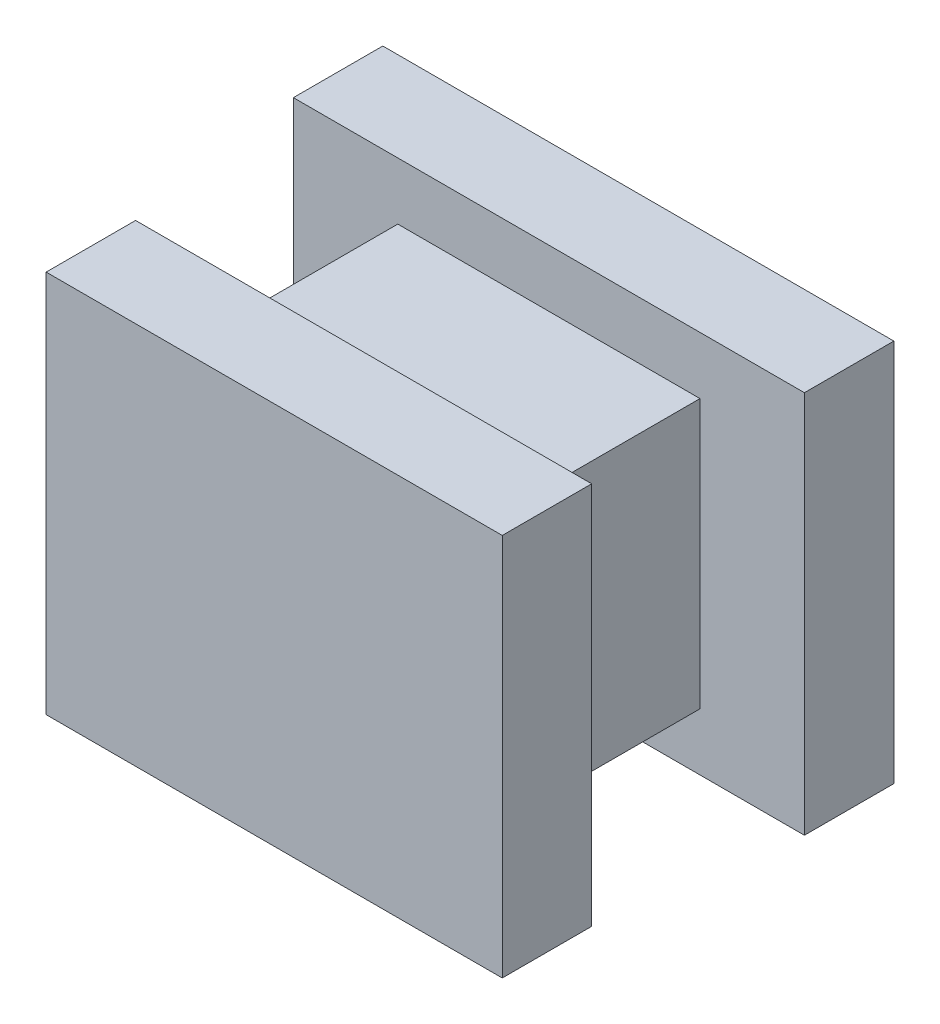
from build123d import *

# Parameters (mm, degrees)
SKETCH_1_W      = 4
SKETCH_1_H      = 3
EXTRUDE_1_DEPTH = 0.7
SKETCH_2_W      = 1.965469396
SKETCH_2_H      = 1.702913888
EXTRUDE_2_DEPTH = 1.45
SKETCH_4_W      = 3.57
SKETCH_4_H      = 3
EXTRUDE_3_DEPTH = 0.7
EXTRUDE_4_REACH = 4.15
SKETCH_7_W      = 2.365469396
SKETCH_7_H      = 2.102913888


with BuildPart() as part:
    # Эскиз1 → Бобышка-Вытянуть1 (new body)
    with BuildSketch(Plane.XY):
        Rectangle(SKETCH_1_W, SKETCH_1_H)
    extrude(amount=EXTRUDE_1_DEPTH)

    # Эскиз2 → Бобышка-Вытянуть2 (add)
    with BuildSketch(Plane.XY.offset(0.7)):
        Rectangle(SKETCH_2_W, SKETCH_2_H)
    extrude(amount=EXTRUDE_2_DEPTH)

    # Эскиз4 → Бобышка-Вытянуть3 (add)
    with BuildSketch(Plane.XY.offset(2.15)):
        Rectangle(SKETCH_4_W, SKETCH_4_H)
    extrude(amount=EXTRUDE_3_DEPTH)


with BuildPart() as body_2:

    # Эскиз7 → Бобышка-Вытянуть4 (new body, up to next)
    with BuildSketch(Plane.XY.offset(0.7), mode=Mode.PRIVATE) as extrude_4_sk1:
        Rectangle(SKETCH_7_W, SKETCH_7_H)
    extrude_4_tool1 = extrude(extrude_4_sk1.sketch, amount=EXTRUDE_4_REACH, mode=Mode.PRIVATE) - part.part
    add(extrude_4_tool1.solids().sort_by_distance((0, 0, 0.7))[0])


solid = Compound([part.part, body_2.part])
